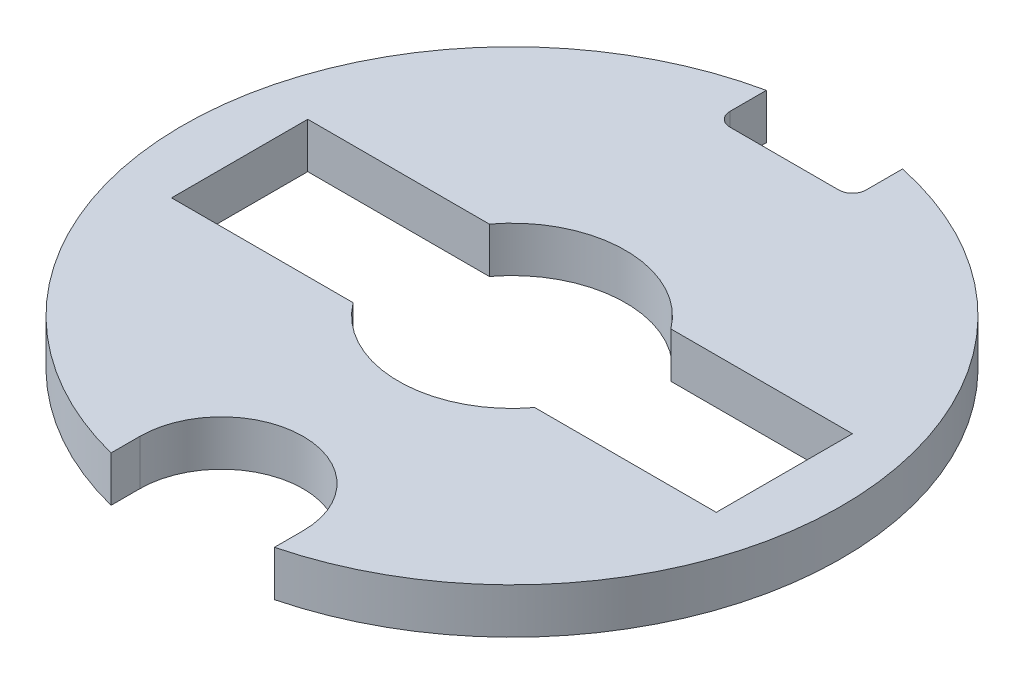
from build123d import *

# Parameters (mm, degrees)
SKETCH1_R           = 7.26
BOSS_EXTRUDE1_DEPTH = 1
CUT_EXTRUDE1_DEPTH  = 2
CUT_EXTRUDE2_DEPTH  = 2
CUT_EXTRUDE3_DEPTH  = 2
FILLET1_R           = 0.3


with BuildPart() as part:
    # Sketch1 → Boss-Extrude1 (new body)
    with BuildSketch(Plane(origin=(0, 0, 0), x_dir=(1, 0, 0), z_dir=(0, 1, 0))):
        Circle(SKETCH1_R)
    extrude(amount=BOSS_EXTRUDE1_DEPTH)

    # Sketch2 → Cut-Extrude1 (cut, through all)
    with BuildSketch(Plane(origin=(0, 1, 0), x_dir=(1, 0, 0), z_dir=(0, 1, 0))):
        with BuildLine():
            Line((-1.5, 7.103351322), (-1.5, 6))
            Line((-1.5, 6), (1.5, 6))
            Line((1.5, 6), (1.5, 7.103351322))
            ThreePointArc((1.5, 7.103351322), (0, 7.26), (-1.5, 7.103351322))
        make_face()
    extrude(amount=-CUT_EXTRUDE1_DEPTH, mode=Mode.SUBTRACT)

    # Sketch3 → Cut-Extrude2 (cut, through all)
    with BuildSketch(Plane(origin=(0, 1, 0), x_dir=(1, 0, 0), z_dir=(0, 1, 0))):
        with BuildLine():
            Line((2, 1.5), (6, 1.5))
            Line((6, 1.5), (6, -1.5))
            Line((6, -1.5), (2, -1.5))
            ThreePointArc((2, -1.5), (0, -2.5), (-2, -1.5))
            Line((-2, -1.5), (-6, -1.5))
            Line((-6, -1.5), (-6, 1.5))
            Line((-6, 1.5), (-2, 1.5))
            ThreePointArc((-2, 1.5), (0, 2.5), (2, 1.5))
        make_face()
    extrude(amount=-CUT_EXTRUDE2_DEPTH, mode=Mode.SUBTRACT)

    # Sketch4 → Cut-Extrude3 (cut, through all)
    with BuildSketch(Plane(origin=(0, 1, 0), x_dir=(1, 0, 0), z_dir=(0, 1, 0))):
        with BuildLine():
            Line((-1.8, -6.4), (-1.8, -7.033320695))
            ThreePointArc((-1.8, -7.033320695), (0, -7.26), (1.8, -7.033320695))
            Line((1.8, -7.033320695), (1.8, -6.4))
            ThreePointArc((1.8, -6.4), (0, -4.6), (-1.8, -6.4))
        make_face()
    extrude(amount=-CUT_EXTRUDE3_DEPTH, mode=Mode.SUBTRACT)

    # Fillet1
    fillet1_edges = [part.edges().sort_by_distance(p)[0] for p in [
        (1.5, 0.5, -6),
        (-1.5, 0.5, -6),
    ]]
    fillet(fillet1_edges, radius=FILLET1_R)


solid = part.part
